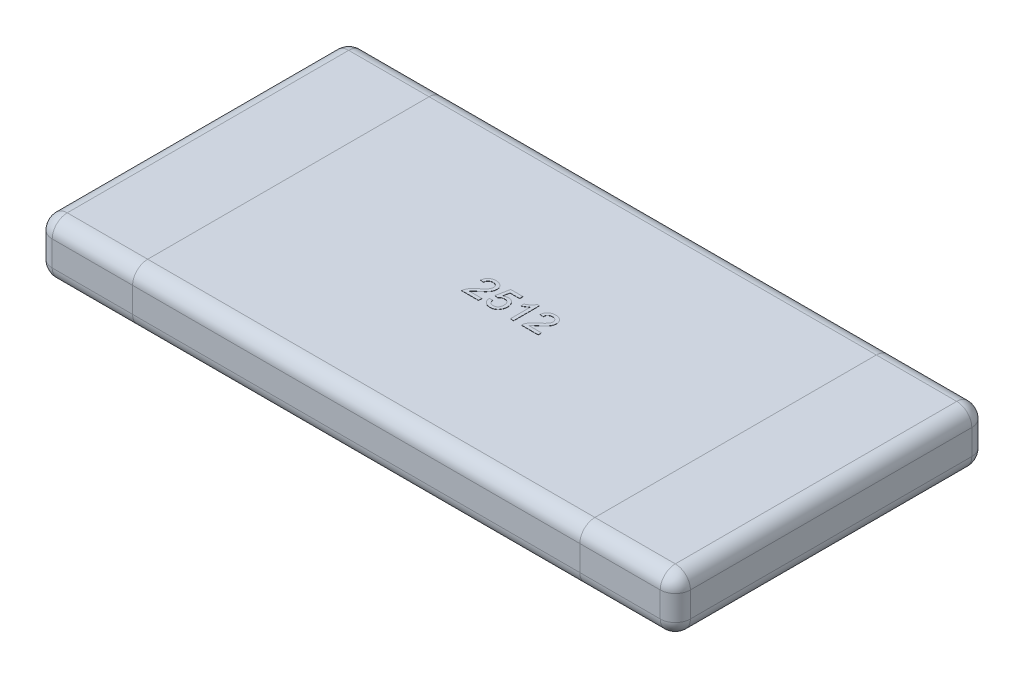
from build123d import *

# Parameters (mm, degrees)
SKETCH1_W      = 6.35
SKETCH1_H      = 3.1
EXTRUDE1_DEPTH = 0.55
FILLET1_R      = 0.15
EXTRUDE2_DEPTH = 0.002


with BuildPart() as part:
    # Sketch1 → Extrude1 (new body)
    with BuildSketch(Plane(origin=(0, 0, 0), x_dir=(1, 0, 0), z_dir=(0, 1, 0))):
        Rectangle(SKETCH1_W, SKETCH1_H)
    extrude(amount=EXTRUDE1_DEPTH)

    # Fillet1
    fillet1_edges = [part.edges().sort_by_distance(p)[0] for p in [
        (3.175, 0.55, 0),
        (0, 0.55, -1.55),
        (-3.175, 0.55, 0),
        (0, 0, -1.55),
        (3.175, 0, 0),
        (0, 0, 1.55),
        (-3.175, 0, 0),
        (0, 0.55, 1.55),
        (-3.175, 0.275, -1.55),
        (3.175, 0.275, -1.55),
        (3.175, 0.275, 1.55),
        (-3.175, 0.275, 1.55),
    ]]
    fillet(fillet1_edges, radius=FILLET1_R)

    # Sketch3 → Extrude2 (add)
    with BuildSketch(Plane(origin=(0, 0.55, 0), x_dir=(1, 0, 0), z_dir=(0, 1, 0))):
        with BuildLine():
            Line((-0.222193322, -0.077072837), (-0.222193322, -0.11))
            Line((-0.222193322, -0.11), (-0.390121851, -0.11))
            add(Edge.make_bspline(
                [(-0.390121851, -0.11), (-0.390125289, -0.108043046), (-0.390132154, -0.104135698), (-0.389470967, -0.098356977), (-0.388435417, -0.092654916), (-0.387264521, -0.088998412), (-0.386674789, -0.087156781)],
                knots=[0, 0, 0, 0, 5.866e-06, 1.1712e-05, 1.7423e-05, 2.3219e-05, 2.3219e-05, 2.3219e-05, 2.3219e-05], degree=3))
            add(Edge.make_bspline(
                [(-0.386674789, -0.087156781), (-0.38558516, -0.084147776), (-0.383366497, -0.078020947), (-0.378871461, -0.069180788), (-0.373584238, -0.060394093), (-0.368436381, -0.053240482), (-0.363722056, -0.047525248), (-0.35976848, -0.043053738), (-0.355387193, -0.038476621), (-0.350581704, -0.033794732), (-0.345398262, -0.02897775), (-0.339829796, -0.024009609), (-0.333810549, -0.018982896), (-0.329608485, -0.015650982), (-0.327457345, -0.013945293)],
                knots=[0, 0, 0, 0, 9.593e-06, 1.9533e-05, 2.9688e-05, 4.034e-05, 4.5933e-05, 5.191e-05, 5.8242e-05, 6.4936e-05, 7.2035e-05, 7.9469e-05, 8.7321e-05, 9.5557e-05, 9.5557e-05, 9.5557e-05, 9.5557e-05], degree=3))
            add(Edge.make_bspline(
                [(-0.327457345, -0.013945293), (-0.324152662, -0.011163795), (-0.317789286, -0.005807844), (-0.308803201, 0.00213989), (-0.300595875, 0.009519812), (-0.293298001, 0.016461269), (-0.286849889, 0.022896933), (-0.281236399, 0.028812225), (-0.276409231, 0.034188683), (-0.272427316, 0.039220912), (-0.269067652, 0.043972737), (-0.266220633, 0.048607848), (-0.26384802, 0.053207211), (-0.261871952, 0.057756273), (-0.260309049, 0.062274487), (-0.259243709, 0.066775017), (-0.258521232, 0.071213207), (-0.258448947, 0.074166427), (-0.258413201, 0.075626879)],
                knots=[0, 0, 0, 0, 1.2958e-05, 2.4951e-05, 3.5988e-05, 4.6068e-05, 5.5163e-05, 6.3315e-05, 7.0531e-05, 7.6831e-05, 8.2555e-05, 8.7981e-05, 9.3136e-05, 9.8067e-05, 0.00010285, 0.000107455, 0.00011193, 0.000116308, 0.000116308, 0.000116308, 0.000116308], degree=3))
            add(Edge.make_bspline(
                [(-0.258413201, 0.075626879), (-0.258448952, 0.077070291), (-0.258519093, 0.079902187), (-0.259184593, 0.084046648), (-0.260111021, 0.088037863), (-0.261608774, 0.091803982), (-0.263391551, 0.095456533), (-0.265678392, 0.098880102), (-0.268323798, 0.102160011), (-0.271352563, 0.105209785), (-0.274660684, 0.10807096), (-0.278357038, 0.110449291), (-0.282198849, 0.112590498), (-0.286318657, 0.114312152), (-0.290709767, 0.115576392), (-0.295340214, 0.116493905), (-0.300209262, 0.117075658), (-0.303532046, 0.117156219), (-0.30523151, 0.117197422)],
                knots=[0, 0, 0, 0, 4.327e-06, 8.489e-06, 1.2569e-05, 1.6591e-05, 2.0618e-05, 2.4742e-05, 2.8912e-05, 3.3241e-05, 3.7622e-05, 4.2003e-05, 4.64e-05, 5.0805e-05, 5.5364e-05, 6.0086e-05, 6.4955e-05, 7.0052e-05, 7.0052e-05, 7.0052e-05, 7.0052e-05], degree=3))
            add(Edge.make_bspline(
                [(-0.30523151, 0.117197422), (-0.30701675, 0.117156423), (-0.310510596, 0.117076184), (-0.315617663, 0.116492111), (-0.320465938, 0.115599727), (-0.325043848, 0.114235348), (-0.329345823, 0.112516566), (-0.33335434, 0.110353077), (-0.337133594, 0.107910889), (-0.34056456, 0.105019523), (-0.343667137, 0.101813587), (-0.346421504, 0.098323293), (-0.348678294, 0.094481286), (-0.350542043, 0.090372041), (-0.352040654, 0.085982642), (-0.353128595, 0.081279532), (-0.353721747, 0.076276291), (-0.353841025, 0.072850072), (-0.353901972, 0.071099394)],
                knots=[0, 0, 0, 0, 5.355e-06, 1.0479e-05, 1.5403e-05, 2.0124e-05, 2.4787e-05, 2.9275e-05, 3.377e-05, 3.8262e-05, 4.2701e-05, 4.7137e-05, 5.1566e-05, 5.6033e-05, 6.0653e-05, 6.5458e-05, 7.0487e-05, 7.5741e-05, 7.5741e-05, 7.5741e-05, 7.5741e-05], degree=3))
            Line((-0.353901972, 0.071099394), (-0.386829135, 0.074392111))
            add(Edge.make_bspline(
                [(-0.386829135, 0.074392111), (-0.386492243, 0.077261793), (-0.38583685, 0.082844514), (-0.384204353, 0.090930145), (-0.381912476, 0.098452099), (-0.379170052, 0.105515248), (-0.375732164, 0.111999357), (-0.371845929, 0.118038542), (-0.367262293, 0.123441265), (-0.362198592, 0.128377828), (-0.356599346, 0.132728239), (-0.350517153, 0.136528926), (-0.343954794, 0.139707967), (-0.33694882, 0.14234008), (-0.329483146, 0.144337131), (-0.321568333, 0.145769204), (-0.313191655, 0.146651951), (-0.307445989, 0.14677104), (-0.304511228, 0.146831868)],
                knots=[0, 0, 0, 0, 8.666e-06, 1.6859e-05, 2.4704e-05, 3.2233e-05, 3.9551e-05, 4.6686e-05, 5.3734e-05, 6.0756e-05, 6.7868e-05, 7.4963e-05, 8.2234e-05, 8.9707e-05, 9.7382e-05, 0.000105385, 0.000113816, 0.000122619, 0.000122619, 0.000122619, 0.000122619], degree=3))
            add(Edge.make_bspline(
                [(-0.304511228, 0.146831868), (-0.30154134, 0.146781013), (-0.295755981, 0.146681945), (-0.287325783, 0.145668283), (-0.279371657, 0.144089514), (-0.271864446, 0.141889194), (-0.264848501, 0.139003918), (-0.258318428, 0.135478762), (-0.252244115, 0.131348113), (-0.246727054, 0.126562386), (-0.241752175, 0.121337963), (-0.237392428, 0.115762377), (-0.233747469, 0.109859447), (-0.230644013, 0.103709635), (-0.228342065, 0.097182999), (-0.226723293, 0.09036827), (-0.22562329, 0.083259624), (-0.225532397, 0.078409379), (-0.225486038, 0.075935571)],
                knots=[0, 0, 0, 0, 8.906e-06, 1.7349e-05, 2.5431e-05, 3.3212e-05, 4.0779e-05, 4.8145e-05, 5.5438e-05, 6.277e-05, 7.0012e-05, 7.7051e-05, 8.3961e-05, 9.0795e-05, 9.7678e-05, 0.000104666, 0.000111789, 0.000119204, 0.000119204, 0.000119204, 0.000119204], degree=3))
            add(Edge.make_bspline(
                [(-0.225486038, 0.075935571), (-0.225556827, 0.073394015), (-0.225698562, 0.068305292), (-0.226804819, 0.060699153), (-0.228697638, 0.053175557), (-0.23120701, 0.045642938), (-0.234635336, 0.038071399), (-0.238966442, 0.030356491), (-0.244339653, 0.022469715), (-0.249507175, 0.015765079), (-0.2543173, 0.010144904), (-0.258581021, 0.005519171), (-0.263513899, 0.00060464), (-0.268930885, -0.004768892), (-0.275052907, -0.010410707), (-0.281704067, -0.016489752), (-0.289029961, -0.02284605), (-0.29411556, -0.027188367), (-0.296742476, -0.029431349)],
                knots=[0, 0, 0, 0, 7.623e-06, 1.5263e-05, 2.2999e-05, 3.0874e-05, 3.9049e-05, 4.7894e-05, 5.7383e-05, 6.7653e-05, 7.3273e-05, 7.9572e-05, 8.652e-05, 9.416e-05, 0.00010246, 0.000111493, 0.000121192, 0.000131555, 0.000131555, 0.000131555, 0.000131555], degree=3))
            add(Edge.make_bspline(
                [(-0.296742476, -0.029431349), (-0.298992033, -0.031262728), (-0.303281592, -0.034754886), (-0.30938432, -0.039817561), (-0.314850508, -0.044459897), (-0.319807983, -0.04853047), (-0.324076195, -0.052226167), (-0.327805487, -0.055385135), (-0.330860372, -0.058166203), (-0.335512421, -0.062390703), (-0.341404638, -0.0684123), (-0.345746275, -0.074263317), (-0.347831027, -0.077072837)],
                knots=[0, 0, 0, 0, 8.702e-06, 1.6594e-05, 2.3787e-05, 3.0217e-05, 3.5836e-05, 4.0724e-05, 4.4878e-05, 4.8228e-05, 5.958e-05, 7.0067e-05, 7.0067e-05, 7.0067e-05, 7.0067e-05], degree=3))
            Line((-0.347831027, -0.077072837), (-0.222193322, -0.077072837))
        make_face()
        with BuildLine():
            Line((-0.185973443, -0.040852958), (-0.15304628, -0.037560242))
            add(Edge.make_bspline(
                [(-0.15304628, -0.037560242), (-0.15272025, -0.039415507), (-0.152086069, -0.043024286), (-0.150877569, -0.0482481), (-0.149308071, -0.05310117), (-0.147544567, -0.057625525), (-0.145448345, -0.061773326), (-0.143177071, -0.065610065), (-0.140498568, -0.068999549), (-0.137682481, -0.072119053), (-0.134591611, -0.074867887), (-0.131196132, -0.077185249), (-0.127590781, -0.079207007), (-0.123731647, -0.080862332), (-0.119612814, -0.082073943), (-0.115286704, -0.08303212), (-0.110697611, -0.08351494), (-0.107566504, -0.083609882), (-0.105970727, -0.08365827)],
                knots=[0, 0, 0, 0, 5.651e-06, 1.0992e-05, 1.6068e-05, 2.0941e-05, 2.5543e-05, 2.9998e-05, 3.429e-05, 3.8477e-05, 4.2596e-05, 4.6664e-05, 5.0786e-05, 5.4981e-05, 5.9229e-05, 6.3649e-05, 6.8257e-05, 7.3046e-05, 7.3046e-05, 7.3046e-05, 7.3046e-05], degree=3))
            add(Edge.make_bspline(
                [(-0.105970727, -0.08365827), (-0.104013068, -0.083610967), (-0.100184778, -0.083518465), (-0.094615343, -0.082736115), (-0.08935456, -0.081446111), (-0.084427601, -0.079640846), (-0.079776709, -0.077395786), (-0.075556172, -0.074488842), (-0.071535865, -0.07122115), (-0.067974495, -0.067325433), (-0.064732647, -0.063084295), (-0.061934689, -0.058454912), (-0.059579203, -0.053502262), (-0.057596142, -0.048227294), (-0.056131796, -0.042599874), (-0.055054651, -0.036649939), (-0.054363167, -0.030373698), (-0.054298049, -0.026071878), (-0.054264792, -0.02387489)],
                knots=[0, 0, 0, 0, 5.871e-06, 1.1481e-05, 1.6834e-05, 2.2091e-05, 2.7199e-05, 3.2279e-05, 3.743e-05, 4.2708e-05, 4.8069e-05, 5.3425e-05, 5.8902e-05, 6.4502e-05, 7.0305e-05, 7.6319e-05, 8.2632e-05, 8.922e-05, 8.922e-05, 8.922e-05, 8.922e-05], degree=3))
            add(Edge.make_bspline(
                [(-0.054264792, -0.02387489), (-0.054302591, -0.021781189), (-0.054376194, -0.017704268), (-0.054996052, -0.011767592), (-0.056041826, -0.00618532), (-0.057394959, -0.000895926), (-0.059260082, 0.004017937), (-0.061472222, 0.008627516), (-0.064182188, 0.012834981), (-0.067197203, 0.016771338), (-0.070640732, 0.020300123), (-0.074559294, 0.023279735), (-0.078799168, 0.025887498), (-0.083445749, 0.02800223), (-0.088501773, 0.029573397), (-0.093916997, 0.030782269), (-0.099747612, 0.031418086), (-0.103757116, 0.031529551), (-0.105816381, 0.031586799)],
                knots=[0, 0, 0, 0, 6.28e-06, 1.2229e-05, 1.788e-05, 2.3308e-05, 2.8583e-05, 3.3622e-05, 3.8618e-05, 4.3568e-05, 4.8479e-05, 5.3357e-05, 5.8298e-05, 6.3387e-05, 6.8626e-05, 7.4156e-05, 8.0008e-05, 8.6187e-05, 8.6187e-05, 8.6187e-05, 8.6187e-05], degree=3))
            add(Edge.make_bspline(
                [(-0.105816381, 0.031586799), (-0.108376978, 0.031511897), (-0.113287621, 0.031368251), (-0.120343712, 0.030159809), (-0.126767126, 0.028207726), (-0.132485139, 0.025298382), (-0.137593901, 0.021822694), (-0.142199544, 0.017889795), (-0.146340046, 0.013502344), (-0.14861128, 0.010199103), (-0.149753564, 0.008537785)],
                knots=[0, 0, 0, 0, 7.677e-06, 1.4723e-05, 2.141e-05, 2.7738e-05, 3.3888e-05, 3.9909e-05, 4.5879e-05, 5.192e-05, 5.192e-05, 5.192e-05, 5.192e-05], degree=3))
            Line((-0.149753564, 0.008537785), (-0.182680727, 0.011830502))
            Line((-0.182680727, 0.011830502), (-0.156338997, 0.143539152))
            Line((-0.156338997, 0.143539152), (-0.034508495, 0.143539152))
            Line((-0.034508495, 0.143539152), (-0.034508495, 0.11061199))
            Line((-0.034508495, 0.11061199), (-0.129431331, 0.11061199))
            Line((-0.129431331, 0.11061199), (-0.142499299, 0.044088831))
            add(Edge.make_bspline(
                [(-0.142499299, 0.044088831), (-0.140682466, 0.045452208), (-0.137114494, 0.048129664), (-0.131549097, 0.05163544), (-0.125904121, 0.054590575), (-0.120212427, 0.057010583), (-0.114428802, 0.058895764), (-0.108588149, 0.060205501), (-0.10267058, 0.061090699), (-0.098702501, 0.061177606), (-0.096709963, 0.061221246)],
                knots=[0, 0, 0, 0, 6.812e-06, 1.3379e-05, 1.9707e-05, 2.5909e-05, 3.1912e-05, 3.7928e-05, 4.3851e-05, 4.9824e-05, 4.9824e-05, 4.9824e-05, 4.9824e-05], degree=3))
            add(Edge.make_bspline(
                [(-0.096709963, 0.061221246), (-0.09411681, 0.061153303), (-0.089010264, 0.061019507), (-0.081485592, 0.059920208), (-0.074290739, 0.058054076), (-0.06736927, 0.055540667), (-0.060812453, 0.052208714), (-0.054553871, 0.048174426), (-0.048618794, 0.04340455), (-0.043040773, 0.037989084), (-0.037981286, 0.031977348), (-0.03345288, 0.025565405), (-0.029754325, 0.018624907), (-0.026643587, 0.011337071), (-0.024297402, 0.003582265), (-0.022516565, -0.004529455), (-0.021564411, -0.013099504), (-0.021414407, -0.018933712), (-0.02133763, -0.02191984)],
                knots=[0, 0, 0, 0, 7.777e-06, 1.5315e-05, 2.2752e-05, 3.0044e-05, 3.7361e-05, 4.4768e-05, 5.2345e-05, 6.0167e-05, 6.8052e-05, 7.5888e-05, 8.3669e-05, 9.16e-05, 9.9623e-05, 0.000107938, 0.000116483, 0.000125442, 0.000125442, 0.000125442, 0.000125442], degree=3))
            add(Edge.make_bspline(
                [(-0.02133763, -0.02191984), (-0.02139593, -0.024769097), (-0.021511091, -0.030397191), (-0.022454855, -0.038691229), (-0.024009483, -0.046683188), (-0.0260907, -0.054396733), (-0.028902704, -0.061788059), (-0.032313402, -0.068881039), (-0.036247832, -0.075749687), (-0.039403042, -0.079983812), (-0.04099103, -0.082114809)],
                knots=[0, 0, 0, 0, 8.546e-06, 1.6881e-05, 2.5003e-05, 3.2954e-05, 4.0818e-05, 4.8689e-05, 5.6551e-05, 6.4517e-05, 6.4517e-05, 6.4517e-05, 6.4517e-05], degree=3))
            add(Edge.make_bspline(
                [(-0.04099103, -0.082114809), (-0.043008525, -0.084602353), (-0.046977153, -0.089495619), (-0.05384879, -0.095846785), (-0.061235897, -0.101244402), (-0.069182436, -0.105629575), (-0.077635058, -0.109153433), (-0.086697603, -0.111498428), (-0.096260565, -0.113073185), (-0.102825724, -0.113218532), (-0.106176522, -0.113292716)],
                knots=[0, 0, 0, 0, 9.598e-06, 1.8881e-05, 2.7978e-05, 3.6983e-05, 4.605e-05, 5.5372e-05, 6.5007e-05, 7.505e-05, 7.505e-05, 7.505e-05, 7.505e-05], degree=3))
            add(Edge.make_bspline(
                [(-0.106176522, -0.113292716), (-0.108940399, -0.113236651), (-0.114347096, -0.113126977), (-0.122263463, -0.112173524), (-0.129792865, -0.110653102), (-0.136937659, -0.108472345), (-0.143719371, -0.105716756), (-0.150059173, -0.102216212), (-0.156067086, -0.098211808), (-0.161610954, -0.093580169), (-0.16666214, -0.088414111), (-0.171188106, -0.082823091), (-0.175127602, -0.076803464), (-0.178478727, -0.07039125), (-0.181271735, -0.063592598), (-0.183408496, -0.056361106), (-0.185100989, -0.048767724), (-0.185679576, -0.043518876), (-0.185973443, -0.040852958)],
                knots=[0, 0, 0, 0, 8.289e-06, 1.6215e-05, 2.3883e-05, 3.1305e-05, 3.8595e-05, 4.5801e-05, 5.2993e-05, 6.0226e-05, 6.7429e-05, 7.4637e-05, 8.1771e-05, 8.8974e-05, 9.6312e-05, 0.000103783, 0.000111573, 0.000119614, 0.000119614, 0.000119614, 0.000119614], degree=3))
        make_face()
        with BuildLine():
            Line((0.126834602, -0.11), (0.093907439, -0.11))
            Line((0.093907439, -0.11), (0.093907439, 0.09013541))
            add(Edge.make_bspline(
                [(0.093907439, 0.09013541), (0.09201149, 0.088307001), (0.088070968, 0.084506852), (0.081409932, 0.079128693), (0.073975364, 0.0736777), (0.065863808, 0.068435961), (0.057595448, 0.06350143), (0.049605143, 0.059063577), (0.042026293, 0.055308077), (0.037034065, 0.053254555), (0.034638547, 0.052269173)],
                knots=[0, 0, 0, 0, 7.899e-06, 1.6416e-05, 2.5657e-05, 3.5546e-05, 4.5375e-05, 5.454e-05, 6.2962e-05, 7.0731e-05, 7.0731e-05, 7.0731e-05, 7.0731e-05], degree=3))
            Line((0.034638547, 0.052269173), (0.034638547, 0.082623901))
            add(Edge.make_bspline(
                [(0.034638547, 0.082623901), (0.038753096, 0.084742903), (0.04686263, 0.088919329), (0.058319647, 0.09613259), (0.069016005, 0.103952063), (0.078774636, 0.112376015), (0.087522628, 0.120986807), (0.094894687, 0.129675434), (0.101063157, 0.138123408), (0.104157996, 0.144014934), (0.105637741, 0.146831868)],
                knots=[0, 0, 0, 0, 1.3879e-05, 2.7355e-05, 4.0567e-05, 5.3592e-05, 6.5998e-05, 7.7348e-05, 8.7755e-05, 9.7289e-05, 9.7289e-05, 9.7289e-05, 9.7289e-05], degree=3))
            Line((0.105637741, 0.146831868), (0.126834602, 0.146831868))
            Line((0.126834602, 0.146831868), (0.126834602, -0.11))
        make_face()
        with BuildLine():
            Line((0.370495605, -0.077072837), (0.370495605, -0.11))
            Line((0.370495605, -0.11), (0.202567076, -0.11))
            add(Edge.make_bspline(
                [(0.202567076, -0.11), (0.202563638, -0.108043046), (0.202556774, -0.104135698), (0.20321796, -0.098356977), (0.20425351, -0.092654916), (0.205424406, -0.088998412), (0.206014138, -0.087156781)],
                knots=[0, 0, 0, 0, 5.866e-06, 1.1712e-05, 1.7423e-05, 2.3219e-05, 2.3219e-05, 2.3219e-05, 2.3219e-05], degree=3))
            add(Edge.make_bspline(
                [(0.206014138, -0.087156781), (0.207103767, -0.084147776), (0.20932243, -0.078020947), (0.213817466, -0.069180788), (0.21910469, -0.060394093), (0.224252546, -0.053240482), (0.228966871, -0.047525248), (0.232920447, -0.043053738), (0.237301734, -0.038476621), (0.242107223, -0.033794732), (0.247290665, -0.02897775), (0.252859132, -0.024009609), (0.258878378, -0.018982896), (0.263080442, -0.015650982), (0.265231582, -0.013945293)],
                knots=[0, 0, 0, 0, 9.593e-06, 1.9533e-05, 2.9688e-05, 4.034e-05, 4.5933e-05, 5.191e-05, 5.8242e-05, 6.4936e-05, 7.2035e-05, 7.9469e-05, 8.7321e-05, 9.5557e-05, 9.5557e-05, 9.5557e-05, 9.5557e-05], degree=3))
            add(Edge.make_bspline(
                [(0.265231582, -0.013945293), (0.268536265, -0.011163795), (0.274899642, -0.005807844), (0.283885726, 0.00213989), (0.292093052, 0.009519812), (0.299390926, 0.016461269), (0.305839038, 0.022896933), (0.311452528, 0.028812225), (0.316279696, 0.034188683), (0.320261611, 0.039220912), (0.323621276, 0.043972737), (0.326468295, 0.048607848), (0.328840907, 0.053207211), (0.330816976, 0.057756273), (0.332379878, 0.062274487), (0.333445219, 0.066775017), (0.334167695, 0.071213207), (0.33423998, 0.074166427), (0.334275727, 0.075626879)],
                knots=[0, 0, 0, 0, 1.2958e-05, 2.4951e-05, 3.5988e-05, 4.6068e-05, 5.5163e-05, 6.3315e-05, 7.0531e-05, 7.6831e-05, 8.2555e-05, 8.7981e-05, 9.3136e-05, 9.8067e-05, 0.00010285, 0.000107455, 0.00011193, 0.000116308, 0.000116308, 0.000116308, 0.000116308], degree=3))
            add(Edge.make_bspline(
                [(0.334275727, 0.075626879), (0.334239976, 0.077070291), (0.334169834, 0.079902187), (0.333504335, 0.084046648), (0.332577906, 0.088037863), (0.331080153, 0.091803982), (0.329297377, 0.095456533), (0.327010535, 0.098880102), (0.32436513, 0.102160011), (0.321336364, 0.105209785), (0.318028243, 0.10807096), (0.314331889, 0.110449291), (0.310490078, 0.112590498), (0.30637027, 0.114312152), (0.30197916, 0.115576392), (0.297348714, 0.116493905), (0.292479665, 0.117075658), (0.289156882, 0.117156219), (0.287457417, 0.117197422)],
                knots=[0, 0, 0, 0, 4.327e-06, 8.489e-06, 1.2569e-05, 1.6591e-05, 2.0618e-05, 2.4742e-05, 2.8912e-05, 3.3241e-05, 3.7622e-05, 4.2003e-05, 4.64e-05, 5.0805e-05, 5.5364e-05, 6.0086e-05, 6.4955e-05, 7.0052e-05, 7.0052e-05, 7.0052e-05, 7.0052e-05], degree=3))
            add(Edge.make_bspline(
                [(0.287457417, 0.117197422), (0.285672177, 0.117156423), (0.282178331, 0.117076184), (0.277071264, 0.116492111), (0.27222299, 0.115599727), (0.267645079, 0.114235348), (0.263343104, 0.112516566), (0.259334587, 0.110353077), (0.255555334, 0.107910889), (0.252124368, 0.105019523), (0.24902179, 0.101813587), (0.246267423, 0.098323293), (0.244010634, 0.094481286), (0.242146884, 0.090372041), (0.240648273, 0.085982642), (0.239560332, 0.081279532), (0.23896718, 0.076276291), (0.238847902, 0.072850072), (0.238786955, 0.071099394)],
                knots=[0, 0, 0, 0, 5.355e-06, 1.0479e-05, 1.5403e-05, 2.0124e-05, 2.4787e-05, 2.9275e-05, 3.377e-05, 3.8262e-05, 4.2701e-05, 4.7137e-05, 5.1566e-05, 5.6033e-05, 6.0653e-05, 6.5458e-05, 7.0487e-05, 7.5741e-05, 7.5741e-05, 7.5741e-05, 7.5741e-05], degree=3))
            Line((0.238786955, 0.071099394), (0.205859792, 0.074392111))
            add(Edge.make_bspline(
                [(0.205859792, 0.074392111), (0.206196684, 0.077261793), (0.206852078, 0.082844514), (0.208484574, 0.090930145), (0.210776451, 0.098452099), (0.213518875, 0.105515248), (0.216956763, 0.111999357), (0.220842999, 0.118038542), (0.225426634, 0.123441265), (0.230490336, 0.128377828), (0.236089581, 0.132728239), (0.242171774, 0.136528926), (0.248734133, 0.139707967), (0.255740108, 0.14234008), (0.263205782, 0.144337131), (0.271120594, 0.145769204), (0.279497272, 0.146651951), (0.285242938, 0.14677104), (0.288177699, 0.146831868)],
                knots=[0, 0, 0, 0, 8.666e-06, 1.6859e-05, 2.4704e-05, 3.2233e-05, 3.9551e-05, 4.6686e-05, 5.3734e-05, 6.0756e-05, 6.7868e-05, 7.4963e-05, 8.2234e-05, 8.9707e-05, 9.7382e-05, 0.000105385, 0.000113816, 0.000122619, 0.000122619, 0.000122619, 0.000122619], degree=3))
            add(Edge.make_bspline(
                [(0.288177699, 0.146831868), (0.291147587, 0.146781013), (0.296932946, 0.146681945), (0.305363145, 0.145668283), (0.31331727, 0.144089514), (0.320824481, 0.141889194), (0.327840426, 0.139003918), (0.3343705, 0.135478762), (0.340444812, 0.131348113), (0.345961874, 0.126562386), (0.350936752, 0.121337963), (0.3552965, 0.115762377), (0.358941458, 0.109859447), (0.362044915, 0.103709635), (0.364346863, 0.097182999), (0.365965635, 0.09036827), (0.367065637, 0.083259624), (0.36715653, 0.078409379), (0.367202889, 0.075935571)],
                knots=[0, 0, 0, 0, 8.906e-06, 1.7349e-05, 2.5431e-05, 3.3212e-05, 4.0779e-05, 4.8145e-05, 5.5438e-05, 6.277e-05, 7.0012e-05, 7.7051e-05, 8.3961e-05, 9.0795e-05, 9.7678e-05, 0.000104666, 0.000111789, 0.000119204, 0.000119204, 0.000119204, 0.000119204], degree=3))
            add(Edge.make_bspline(
                [(0.367202889, 0.075935571), (0.3671321, 0.073394015), (0.366990365, 0.068305292), (0.365884108, 0.060699153), (0.363991289, 0.053175557), (0.361481917, 0.045642938), (0.358053592, 0.038071399), (0.353722485, 0.030356491), (0.348349274, 0.022469715), (0.343181752, 0.015765079), (0.338371627, 0.010144904), (0.334107906, 0.005519171), (0.329175028, 0.00060464), (0.323758043, -0.004768892), (0.31763602, -0.010410707), (0.31098486, -0.016489752), (0.303658966, -0.02284605), (0.298573367, -0.027188367), (0.295946451, -0.029431349)],
                knots=[0, 0, 0, 0, 7.623e-06, 1.5263e-05, 2.2999e-05, 3.0874e-05, 3.9049e-05, 4.7894e-05, 5.7383e-05, 6.7653e-05, 7.3273e-05, 7.9572e-05, 8.652e-05, 9.416e-05, 0.00010246, 0.000111493, 0.000121192, 0.000131555, 0.000131555, 0.000131555, 0.000131555], degree=3))
            add(Edge.make_bspline(
                [(0.295946451, -0.029431349), (0.293696894, -0.031262728), (0.289407336, -0.034754886), (0.283304607, -0.039817561), (0.277838419, -0.044459897), (0.272880945, -0.04853047), (0.268612732, -0.052226167), (0.26488344, -0.055385135), (0.261828555, -0.058166203), (0.257176506, -0.062390703), (0.251284289, -0.0684123), (0.246942652, -0.074263317), (0.244857901, -0.077072837)],
                knots=[0, 0, 0, 0, 8.702e-06, 1.6594e-05, 2.3787e-05, 3.0217e-05, 3.5836e-05, 4.0724e-05, 4.4878e-05, 4.8228e-05, 5.958e-05, 7.0067e-05, 7.0067e-05, 7.0067e-05, 7.0067e-05], degree=3))
            Line((0.244857901, -0.077072837), (0.370495605, -0.077072837))
        make_face()
    extrude(amount=EXTRUDE2_DEPTH)


solid = part.part
